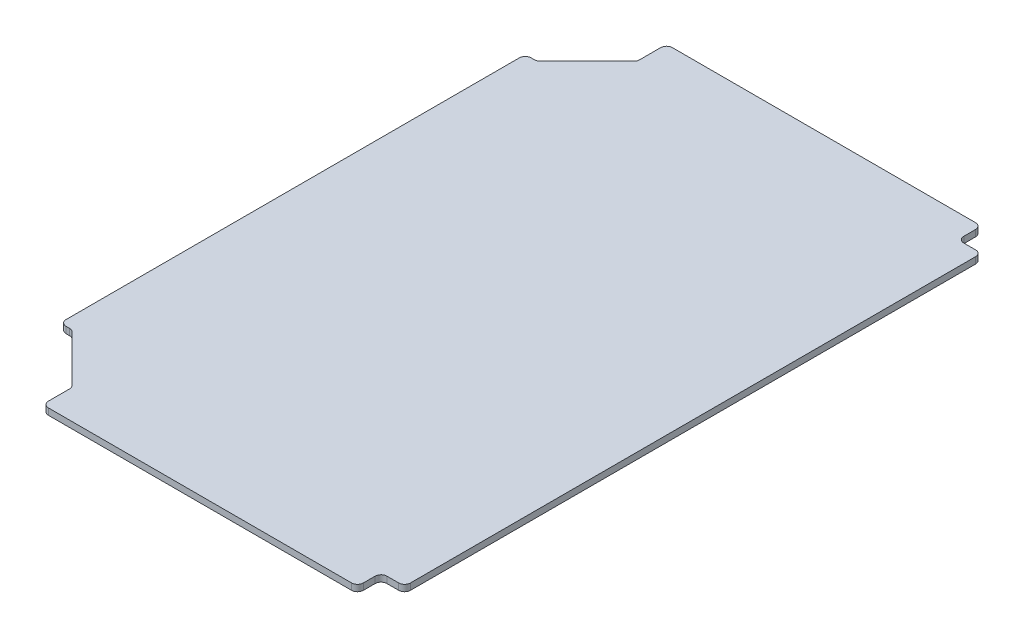
from build123d import *

# Parameters (mm, degrees)
SKETCH1_W           = 190.5
SKETCH1_H           = 304.8
BOSS_EXTRUDE1_DEPTH = 2.778125
SKETCH2_W           = 190.5
SKETCH2_H           = 17.78
CUT_EXTRUDE1_DEPTH  = 3.778125
SKETCH3_W           = 17.78
SKETCH3_H           = 269.24
CUT_EXTRUDE2_DEPTH  = 3.778125
CUT_EXTRUDE3_DEPTH  = 3.778125
SKETCH5_W           = 10.16
SKETCH5_H           = 10.16
CUT_EXTRUDE4_DEPTH  = 3.778125
FILLET1_R           = 2.54


with BuildPart() as part:
    # Sketch1 → Boss-Extrude1 (new body)
    with BuildSketch(Plane(origin=(0, 0, 0), x_dir=(1, 0, 0), z_dir=(0, 1, 0))):
        with Locations((95.25, 152.4)):
            Rectangle(SKETCH1_W, SKETCH1_H)
    extrude(amount=BOSS_EXTRUDE1_DEPTH)

    # Sketch2 → Cut-Extrude1 (cut, through all)
    with BuildSketch(Plane(origin=(0, 2.778125, 0), x_dir=(1, 0, 0), z_dir=(0, 1, 0))):
        with Locations((95.25, 8.89)):
            Rectangle(SKETCH2_W, SKETCH2_H)
        with Locations((95.25, 295.91)):
            Rectangle(SKETCH2_W, SKETCH2_H)
    extrude(amount=-CUT_EXTRUDE1_DEPTH, mode=Mode.SUBTRACT)

    # Sketch3 → Cut-Extrude2 (cut, through all)
    with BuildSketch(Plane(origin=(0, 2.778125, 0), x_dir=(1, 0, 0), z_dir=(0, 1, 0))):
        with Locations((8.89, 152.4)):
            Rectangle(SKETCH3_W, SKETCH3_H)
    extrude(amount=-CUT_EXTRUDE2_DEPTH, mode=Mode.SUBTRACT)

    # Sketch4 → Cut-Extrude3 (cut, through all)
    with BuildSketch(Plane(origin=(0, 2.778125, 0), x_dir=(1, 0, 0), z_dir=(0, 1, 0))):
        Polygon((22.86, 252.73), (44.45, 274.32), (44.45, 287.02), (17.78, 287.02), (17.78, 252.73), align=None)
        Polygon((22.86, 52.07), (44.45, 30.48), (44.45, 17.78), (17.78, 17.78), (17.78, 52.07), align=None)
    extrude(amount=-CUT_EXTRUDE3_DEPTH, mode=Mode.SUBTRACT)

    # Sketch5 → Cut-Extrude4 (cut, through all)
    with BuildSketch(Plane(origin=(0, 2.778125, 0), x_dir=(1, 0, 0), z_dir=(0, 1, 0))):
        with Locations((185.42, 281.94)):
            Rectangle(SKETCH5_W, SKETCH5_H)
        with Locations((185.42, 22.86)):
            Rectangle(SKETCH5_W, SKETCH5_H)
    extrude(amount=-CUT_EXTRUDE4_DEPTH, mode=Mode.SUBTRACT)

    # Fillet1
    fillet1_edges = [part.edges().sort_by_distance(p)[0] for p in [
        (190.5, 1.3890625, -27.94),
        (180.34, 1.3890625, -17.78),
        (180.34, 1.3890625, -27.94),
        (44.45, 1.3890625, -287.02),
        (44.45, 1.3890625, -274.32),
        (22.86, 1.3890625, -252.73),
        (17.78, 1.3890625, -252.73),
        (17.78, 1.3890625, -52.07),
        (22.86, 1.3890625, -52.07),
        (44.45, 1.3890625, -30.48),
        (44.45, 1.3890625, -17.78),
        (190.5, 1.3890625, -276.86),
        (180.34, 1.3890625, -276.86),
        (180.34, 1.3890625, -287.02),
    ]]
    fillet(fillet1_edges, radius=FILLET1_R)


solid = part.part
